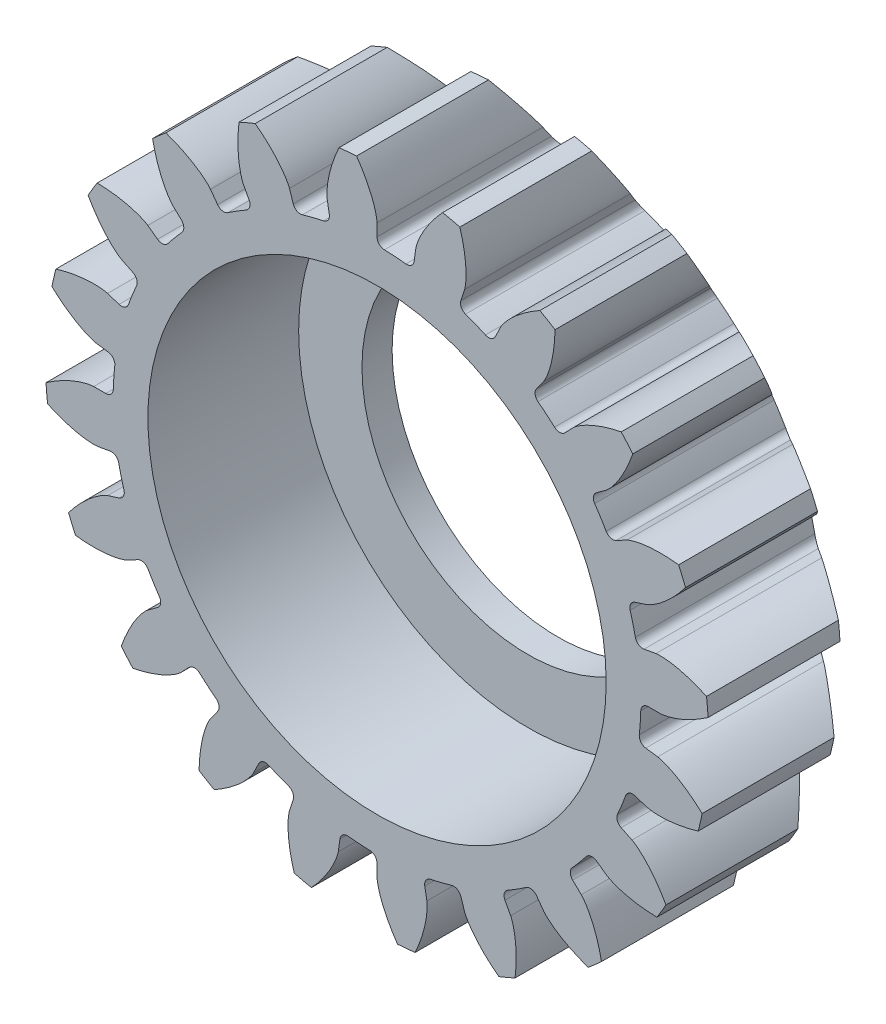
from build123d import *

# Parameters (mm, degrees)
BOSS_EXTRUDE3_DEPTH       = 6
FILLET1_R                 = 0.25
CIRPATTERN8_COUNT         = 20
CIRPATTERN8_COPY_1_DEPTH  = 6
CIRPATTERN8_COPY_2_DEPTH  = 6
CIRPATTERN8_COPY_3_DEPTH  = 6
CIRPATTERN8_COPY_4_DEPTH  = 6
CIRPATTERN8_COPY_5_DEPTH  = 6
CIRPATTERN8_COPY_6_DEPTH  = 6
CIRPATTERN8_COPY_7_DEPTH  = 6
CIRPATTERN8_COPY_8_DEPTH  = 6
CIRPATTERN8_COPY_9_DEPTH  = 6
CIRPATTERN8_COPY_10_DEPTH = 6
CIRPATTERN8_COPY_11_DEPTH = 6
CIRPATTERN8_COPY_12_DEPTH = 6
CIRPATTERN8_COPY_13_DEPTH = 6
CIRPATTERN8_COPY_14_DEPTH = 6
CIRPATTERN8_COPY_15_DEPTH = 6
CIRPATTERN8_COPY_16_DEPTH = 6
CIRPATTERN8_COPY_17_DEPTH = 6
CIRPATTERN8_COPY_18_DEPTH = 6
CIRPATTERN8_COPY_19_DEPTH = 6
FILLET1_OF_CIRPATTERN8_R  = 0.25
SKETCH3_R                 = 7.6
CUT_EXTRUDE2_DEPTH        = 7.0000001
SKETCH6_R                 = 7.6
SKETCH6_R_2               = 5.5
BOSS_EXTRUDE5_DEPTH       = 1


with BuildPart() as part:
    # Sketch1 → Boss-Extrude3 (new body)
    with BuildSketch(Plane.XY):
        with BuildLine():
            Line((8.75, 0), (9.396926208, 0))
            add(Edge.make_bspline(
                [(9.396926208, 0), (9.403873385, 0.000147014), (9.423343335, 0.001014311), (9.460070906, 0.004449694), (9.519753567, 0.012596883), (9.595337479, 0.026698157), (9.692315433, 0.04916848), (9.805467589, 0.081058111), (9.928458206, 0.121729349), (10.060578251, 0.171978374), (10.190725417, 0.227360837), (10.318851863, 0.287431588), (10.444850985, 0.351585639), (10.595383311, 0.434313207), (10.745012763, 0.523787061), (10.861917766, 0.599620812), (10.947597548, 0.658189386), (10.978959632, 0.680033385)],
                knots=[0, 0, 0, 0, 0, 0.005376748, 0.015083688, 0.02853182, 0.046610139, 0.064854849, 0.092110525, 0.119476175, 0.146842495, 0.174208853, 0.201574955, 0.228941013, 0.256307345, 0.307035032, 0.336624535, 0.336624535, 0.336624535, 0.336624535, 0.336624535], degree=4))
            ThreePointArc((10.978959632, 0.680033385), (10.968951272, 0.825898301), (10.957005057, 0.971617307))
            Line((10.957005057, 0.971617307), (8.715799477, 0.772877403))
            ThreePointArc((8.715799477, 0.772877403), (8.741445688, 0.386816868), (8.75, 0))
        make_face()
        with BuildLine():
            ThreePointArc((-8.715799477, -0.772877403), (0.386816868, -8.741445688), (8.75, 0))
            ThreePointArc((8.75, 0), (8.741445688, 0.386816868), (8.715799477, 0.772877403))
            Line((8.715799477, 0.772877403), (-8.715799477, -0.772877403))
        make_face()
        with BuildLine():
            Line((-8.715799477, -0.772877403), (8.715799477, 0.772877403))
            ThreePointArc((8.715799477, 0.772877403), (-0.772877403, 8.715799477), (-8.715799477, -0.772877403))
        make_face()
    boss_extrude3 = extrude(amount=BOSS_EXTRUDE3_DEPTH)

    # Mirror2: Boss-Extrude3 across plane
    add(boss_extrude3.mirror(Plane(origin=(0, 0, 6), x_dir=(0, 0, 1), z_dir=(0.088328846, -0.996091369, 0))))

    # Fillet1
    fillet1_edges = [part.edges().sort_by_distance(p)[0] for p in [
        (8.75, 0, 3),
        (8.613465262, 1.539713021, 3),
    ]]
    fillet(fillet1_edges, radius=FILLET1_R)

    # CirPattern8: Boss-Extrude3 ×20 about axis
    cirpattern8_axis = Axis((0, 0, 6), (0, 0, -1))
    for i in range(1, CIRPATTERN8_COUNT):
        add(boss_extrude3.rotate(cirpattern8_axis, i * 360 / CIRPATTERN8_COUNT))

    # CirPattern8 copy 1 sketch → CirPattern8 copy 1 (add)
    with BuildSketch(Plane(origin=(0, 0, 0), x_dir=(0.990593115, -0.136840348, 0), z_dir=(0, 0, 1))):
        with BuildLine():
            Line((8.75, 0), (9.396926208, 0))
            add(Edge.make_bspline(
                [(9.396926208, 0), (9.403873385, -0.000147014), (9.423343335, -0.001014311), (9.460070906, -0.004449694), (9.519753567, -0.012596883), (9.595337479, -0.026698157), (9.692315433, -0.04916848), (9.805467589, -0.081058111), (9.928458206, -0.121729349), (10.060578251, -0.171978374), (10.190725417, -0.227360837), (10.318851863, -0.287431588), (10.444850985, -0.351585639), (10.595383311, -0.434313207), (10.745012763, -0.523787061), (10.861917766, -0.599620812), (10.947597548, -0.658189386), (10.978959632, -0.680033385)],
                knots=[0, 0, 0, 0, 0, 0.005376748, 0.015083688, 0.02853182, 0.046610139, 0.064854849, 0.092110525, 0.119476175, 0.146842495, 0.174208853, 0.201574955, 0.228941013, 0.256307345, 0.307035032, 0.336624535, 0.336624535, 0.336624535, 0.336624535, 0.336624535], degree=4))
            ThreePointArc((10.978959632, -0.680033385), (10.968951272, -0.825898301), (10.957005057, -0.971617307))
            Line((10.957005057, -0.971617307), (8.715799477, -0.772877403))
            ThreePointArc((8.715799477, -0.772877403), (8.741445688, -0.386816868), (8.75, 0))
        make_face()
        with BuildLine():
            ThreePointArc((-8.715799477, 0.772877403), (0.386816868, 8.741445688), (8.75, 0))
            ThreePointArc((8.75, 0), (8.741445688, -0.386816868), (8.715799477, -0.772877403))
            Line((8.715799477, -0.772877403), (-8.715799477, 0.772877403))
        make_face()
        with BuildLine():
            Line((-8.715799477, 0.772877403), (8.715799477, -0.772877403))
            ThreePointArc((8.715799477, -0.772877403), (-0.772877403, -8.715799477), (-8.715799477, 0.772877403))
        make_face()
    extrude(amount=CIRPATTERN8_COPY_1_DEPTH)

    # CirPattern8 copy 2 sketch → CirPattern8 copy 2 (add)
    with BuildSketch(Plane(origin=(0, 0, 0), x_dir=(0.899824044, -0.436253012, 0), z_dir=(0, 0, 1))):
        with BuildLine():
            Line((8.75, 0), (9.396926208, 0))
            add(Edge.make_bspline(
                [(9.396926208, 0), (9.403873385, -0.000147014), (9.423343335, -0.001014311), (9.460070906, -0.004449694), (9.519753567, -0.012596883), (9.595337479, -0.026698157), (9.692315433, -0.04916848), (9.805467589, -0.081058111), (9.928458206, -0.121729349), (10.060578251, -0.171978374), (10.190725417, -0.227360837), (10.318851863, -0.287431588), (10.444850985, -0.351585639), (10.595383311, -0.434313207), (10.745012763, -0.523787061), (10.861917766, -0.599620812), (10.947597548, -0.658189386), (10.978959632, -0.680033385)],
                knots=[0, 0, 0, 0, 0, 0.005376748, 0.015083688, 0.02853182, 0.046610139, 0.064854849, 0.092110525, 0.119476175, 0.146842495, 0.174208853, 0.201574955, 0.228941013, 0.256307345, 0.307035032, 0.336624535, 0.336624535, 0.336624535, 0.336624535, 0.336624535], degree=4))
            ThreePointArc((10.978959632, -0.680033385), (10.968951272, -0.825898301), (10.957005057, -0.971617307))
            Line((10.957005057, -0.971617307), (8.715799477, -0.772877403))
            ThreePointArc((8.715799477, -0.772877403), (8.741445688, -0.386816868), (8.75, 0))
        make_face()
        with BuildLine():
            ThreePointArc((-8.715799477, 0.772877403), (0.386816868, 8.741445688), (8.75, 0))
            ThreePointArc((8.75, 0), (8.741445688, -0.386816868), (8.715799477, -0.772877403))
            Line((8.715799477, -0.772877403), (-8.715799477, 0.772877403))
        make_face()
        with BuildLine():
            Line((-8.715799477, 0.772877403), (8.715799477, -0.772877403))
            ThreePointArc((8.715799477, -0.772877403), (-0.772877403, -8.715799477), (-8.715799477, 0.772877403))
        make_face()
    extrude(amount=CIRPATTERN8_COPY_2_DEPTH)

    # CirPattern8 copy 3 sketch → CirPattern8 copy 3 (add)
    with BuildSketch(Plane(origin=(0, 0, 0), x_dir=(0.720973926, -0.692962191, 0), z_dir=(0, 0, 1))):
        with BuildLine():
            Line((8.75, 0), (9.396926208, 0))
            add(Edge.make_bspline(
                [(9.396926208, 0), (9.403873385, -0.000147014), (9.423343335, -0.001014311), (9.460070906, -0.004449694), (9.519753567, -0.012596883), (9.595337479, -0.026698157), (9.692315433, -0.04916848), (9.805467589, -0.081058111), (9.928458206, -0.121729349), (10.060578251, -0.171978374), (10.190725417, -0.227360837), (10.318851863, -0.287431588), (10.444850985, -0.351585639), (10.595383311, -0.434313207), (10.745012763, -0.523787061), (10.861917766, -0.599620812), (10.947597548, -0.658189386), (10.978959632, -0.680033385)],
                knots=[0, 0, 0, 0, 0, 0.005376748, 0.015083688, 0.02853182, 0.046610139, 0.064854849, 0.092110525, 0.119476175, 0.146842495, 0.174208853, 0.201574955, 0.228941013, 0.256307345, 0.307035032, 0.336624535, 0.336624535, 0.336624535, 0.336624535, 0.336624535], degree=4))
            ThreePointArc((10.978959632, -0.680033385), (10.968951272, -0.825898301), (10.957005057, -0.971617307))
            Line((10.957005057, -0.971617307), (8.715799477, -0.772877403))
            ThreePointArc((8.715799477, -0.772877403), (8.741445688, -0.386816868), (8.75, 0))
        make_face()
        with BuildLine():
            ThreePointArc((-8.715799477, 0.772877403), (0.386816868, 8.741445688), (8.75, 0))
            ThreePointArc((8.75, 0), (8.741445688, -0.386816868), (8.715799477, -0.772877403))
            Line((8.715799477, -0.772877403), (-8.715799477, 0.772877403))
        make_face()
        with BuildLine():
            Line((-8.715799477, 0.772877403), (8.715799477, -0.772877403))
            ThreePointArc((8.715799477, -0.772877403), (-0.772877403, -8.715799477), (-8.715799477, 0.772877403))
        make_face()
    extrude(amount=CIRPATTERN8_COPY_3_DEPTH)

    # CirPattern8 copy 4 sketch → CirPattern8 copy 4 (add)
    with BuildSketch(Plane(origin=(0, 0, 0), x_dir=(0.471549857, -0.881839403, 0), z_dir=(0, 0, 1))):
        with BuildLine():
            Line((8.75, 0), (9.396926208, 0))
            add(Edge.make_bspline(
                [(9.396926208, 0), (9.403873385, -0.000147014), (9.423343335, -0.001014311), (9.460070906, -0.004449694), (9.519753567, -0.012596883), (9.595337479, -0.026698157), (9.692315433, -0.04916848), (9.805467589, -0.081058111), (9.928458206, -0.121729349), (10.060578251, -0.171978374), (10.190725417, -0.227360837), (10.318851863, -0.287431588), (10.444850985, -0.351585639), (10.595383311, -0.434313207), (10.745012763, -0.523787061), (10.861917766, -0.599620812), (10.947597548, -0.658189386), (10.978959632, -0.680033385)],
                knots=[0, 0, 0, 0, 0, 0.005376748, 0.015083688, 0.02853182, 0.046610139, 0.064854849, 0.092110525, 0.119476175, 0.146842495, 0.174208853, 0.201574955, 0.228941013, 0.256307345, 0.307035032, 0.336624535, 0.336624535, 0.336624535, 0.336624535, 0.336624535], degree=4))
            ThreePointArc((10.978959632, -0.680033385), (10.968951272, -0.825898301), (10.957005057, -0.971617307))
            Line((10.957005057, -0.971617307), (8.715799477, -0.772877403))
            ThreePointArc((8.715799477, -0.772877403), (8.741445688, -0.386816868), (8.75, 0))
        make_face()
        with BuildLine():
            ThreePointArc((-8.715799477, 0.772877403), (0.386816868, 8.741445688), (8.75, 0))
            ThreePointArc((8.75, 0), (8.741445688, -0.386816868), (8.715799477, -0.772877403))
            Line((8.715799477, -0.772877403), (-8.715799477, 0.772877403))
        make_face()
        with BuildLine():
            Line((-8.715799477, 0.772877403), (8.715799477, -0.772877403))
            ThreePointArc((8.715799477, -0.772877403), (-0.772877403, -8.715799477), (-8.715799477, 0.772877403))
        make_face()
    extrude(amount=CIRPATTERN8_COPY_4_DEPTH)

    # CirPattern8 copy 5 sketch → CirPattern8 copy 5 (add)
    with BuildSketch(Plane(origin=(0, 0, 0), x_dir=(0.175967202, -0.98439603, 0), z_dir=(0, 0, 1))):
        with BuildLine():
            Line((8.75, 0), (9.396926208, 0))
            add(Edge.make_bspline(
                [(9.396926208, 0), (9.403873385, -0.000147014), (9.423343335, -0.001014311), (9.460070906, -0.004449694), (9.519753567, -0.012596883), (9.595337479, -0.026698157), (9.692315433, -0.04916848), (9.805467589, -0.081058111), (9.928458206, -0.121729349), (10.060578251, -0.171978374), (10.190725417, -0.227360837), (10.318851863, -0.287431588), (10.444850985, -0.351585639), (10.595383311, -0.434313207), (10.745012763, -0.523787061), (10.861917766, -0.599620812), (10.947597548, -0.658189386), (10.978959632, -0.680033385)],
                knots=[0, 0, 0, 0, 0, 0.005376748, 0.015083688, 0.02853182, 0.046610139, 0.064854849, 0.092110525, 0.119476175, 0.146842495, 0.174208853, 0.201574955, 0.228941013, 0.256307345, 0.307035032, 0.336624535, 0.336624535, 0.336624535, 0.336624535, 0.336624535], degree=4))
            ThreePointArc((10.978959632, -0.680033385), (10.968951272, -0.825898301), (10.957005057, -0.971617307))
            Line((10.957005057, -0.971617307), (8.715799477, -0.772877403))
            ThreePointArc((8.715799477, -0.772877403), (8.741445688, -0.386816868), (8.75, 0))
        make_face()
        with BuildLine():
            ThreePointArc((-8.715799477, 0.772877403), (0.386816868, 8.741445688), (8.75, 0))
            ThreePointArc((8.75, 0), (8.741445688, -0.386816868), (8.715799477, -0.772877403))
            Line((8.715799477, -0.772877403), (-8.715799477, 0.772877403))
        make_face()
        with BuildLine():
            Line((-8.715799477, 0.772877403), (8.715799477, -0.772877403))
            ThreePointArc((8.715799477, -0.772877403), (-0.772877403, -8.715799477), (-8.715799477, 0.772877403))
        make_face()
    extrude(amount=CIRPATTERN8_COPY_5_DEPTH)

    # CirPattern8 copy 6 sketch → CirPattern8 copy 6 (add)
    with BuildSketch(Plane(origin=(0, 0, 0), x_dir=(-0.136840348, -0.990593115, 0), z_dir=(0, 0, 1))):
        with BuildLine():
            Line((8.75, 0), (9.396926208, 0))
            add(Edge.make_bspline(
                [(9.396926208, 0), (9.403873385, -0.000147014), (9.423343335, -0.001014311), (9.460070906, -0.004449694), (9.519753567, -0.012596883), (9.595337479, -0.026698157), (9.692315433, -0.04916848), (9.805467589, -0.081058111), (9.928458206, -0.121729349), (10.060578251, -0.171978374), (10.190725417, -0.227360837), (10.318851863, -0.287431588), (10.444850985, -0.351585639), (10.595383311, -0.434313207), (10.745012763, -0.523787061), (10.861917766, -0.599620812), (10.947597548, -0.658189386), (10.978959632, -0.680033385)],
                knots=[0, 0, 0, 0, 0, 0.005376748, 0.015083688, 0.02853182, 0.046610139, 0.064854849, 0.092110525, 0.119476175, 0.146842495, 0.174208853, 0.201574955, 0.228941013, 0.256307345, 0.307035032, 0.336624535, 0.336624535, 0.336624535, 0.336624535, 0.336624535], degree=4))
            ThreePointArc((10.978959632, -0.680033385), (10.968951272, -0.825898301), (10.957005057, -0.971617307))
            Line((10.957005057, -0.971617307), (8.715799477, -0.772877403))
            ThreePointArc((8.715799477, -0.772877403), (8.741445688, -0.386816868), (8.75, 0))
        make_face()
        with BuildLine():
            ThreePointArc((-8.715799477, 0.772877403), (0.386816868, 8.741445688), (8.75, 0))
            ThreePointArc((8.75, 0), (8.741445688, -0.386816868), (8.715799477, -0.772877403))
            Line((8.715799477, -0.772877403), (-8.715799477, 0.772877403))
        make_face()
        with BuildLine():
            Line((-8.715799477, 0.772877403), (8.715799477, -0.772877403))
            ThreePointArc((8.715799477, -0.772877403), (-0.772877403, -8.715799477), (-8.715799477, 0.772877403))
        make_face()
    extrude(amount=CIRPATTERN8_COPY_6_DEPTH)

    # CirPattern8 copy 7 sketch → CirPattern8 copy 7 (add)
    with BuildSketch(Plane(origin=(0, 0, 0), x_dir=(-0.436253012, -0.899824044, 0), z_dir=(0, 0, 1))):
        with BuildLine():
            Line((8.75, 0), (9.396926208, 0))
            add(Edge.make_bspline(
                [(9.396926208, 0), (9.403873385, -0.000147014), (9.423343335, -0.001014311), (9.460070906, -0.004449694), (9.519753567, -0.012596883), (9.595337479, -0.026698157), (9.692315433, -0.04916848), (9.805467589, -0.081058111), (9.928458206, -0.121729349), (10.060578251, -0.171978374), (10.190725417, -0.227360837), (10.318851863, -0.287431588), (10.444850985, -0.351585639), (10.595383311, -0.434313207), (10.745012763, -0.523787061), (10.861917766, -0.599620812), (10.947597548, -0.658189386), (10.978959632, -0.680033385)],
                knots=[0, 0, 0, 0, 0, 0.005376748, 0.015083688, 0.02853182, 0.046610139, 0.064854849, 0.092110525, 0.119476175, 0.146842495, 0.174208853, 0.201574955, 0.228941013, 0.256307345, 0.307035032, 0.336624535, 0.336624535, 0.336624535, 0.336624535, 0.336624535], degree=4))
            ThreePointArc((10.978959632, -0.680033385), (10.968951272, -0.825898301), (10.957005057, -0.971617307))
            Line((10.957005057, -0.971617307), (8.715799477, -0.772877403))
            ThreePointArc((8.715799477, -0.772877403), (8.741445688, -0.386816868), (8.75, 0))
        make_face()
        with BuildLine():
            ThreePointArc((-8.715799477, 0.772877403), (0.386816868, 8.741445688), (8.75, 0))
            ThreePointArc((8.75, 0), (8.741445688, -0.386816868), (8.715799477, -0.772877403))
            Line((8.715799477, -0.772877403), (-8.715799477, 0.772877403))
        make_face()
        with BuildLine():
            Line((-8.715799477, 0.772877403), (8.715799477, -0.772877403))
            ThreePointArc((8.715799477, -0.772877403), (-0.772877403, -8.715799477), (-8.715799477, 0.772877403))
        make_face()
    extrude(amount=CIRPATTERN8_COPY_7_DEPTH)

    # CirPattern8 copy 8 sketch → CirPattern8 copy 8 (add)
    with BuildSketch(Plane(origin=(0, 0, 0), x_dir=(-0.692962191, -0.720973926, 0), z_dir=(0, 0, 1))):
        with BuildLine():
            Line((8.75, 0), (9.396926208, 0))
            add(Edge.make_bspline(
                [(9.396926208, 0), (9.403873385, -0.000147014), (9.423343335, -0.001014311), (9.460070906, -0.004449694), (9.519753567, -0.012596883), (9.595337479, -0.026698157), (9.692315433, -0.04916848), (9.805467589, -0.081058111), (9.928458206, -0.121729349), (10.060578251, -0.171978374), (10.190725417, -0.227360837), (10.318851863, -0.287431588), (10.444850985, -0.351585639), (10.595383311, -0.434313207), (10.745012763, -0.523787061), (10.861917766, -0.599620812), (10.947597548, -0.658189386), (10.978959632, -0.680033385)],
                knots=[0, 0, 0, 0, 0, 0.005376748, 0.015083688, 0.02853182, 0.046610139, 0.064854849, 0.092110525, 0.119476175, 0.146842495, 0.174208853, 0.201574955, 0.228941013, 0.256307345, 0.307035032, 0.336624535, 0.336624535, 0.336624535, 0.336624535, 0.336624535], degree=4))
            ThreePointArc((10.978959632, -0.680033385), (10.968951272, -0.825898301), (10.957005057, -0.971617307))
            Line((10.957005057, -0.971617307), (8.715799477, -0.772877403))
            ThreePointArc((8.715799477, -0.772877403), (8.741445688, -0.386816868), (8.75, 0))
        make_face()
        with BuildLine():
            ThreePointArc((-8.715799477, 0.772877403), (0.386816868, 8.741445688), (8.75, 0))
            ThreePointArc((8.75, 0), (8.741445688, -0.386816868), (8.715799477, -0.772877403))
            Line((8.715799477, -0.772877403), (-8.715799477, 0.772877403))
        make_face()
        with BuildLine():
            Line((-8.715799477, 0.772877403), (8.715799477, -0.772877403))
            ThreePointArc((8.715799477, -0.772877403), (-0.772877403, -8.715799477), (-8.715799477, 0.772877403))
        make_face()
    extrude(amount=CIRPATTERN8_COPY_8_DEPTH)

    # CirPattern8 copy 9 sketch → CirPattern8 copy 9 (add)
    with BuildSketch(Plane(origin=(0, 0, 0), x_dir=(-0.881839403, -0.471549857, 0), z_dir=(0, 0, 1))):
        with BuildLine():
            Line((8.75, 0), (9.396926208, 0))
            add(Edge.make_bspline(
                [(9.396926208, 0), (9.403873385, -0.000147014), (9.423343335, -0.001014311), (9.460070906, -0.004449694), (9.519753567, -0.012596883), (9.595337479, -0.026698157), (9.692315433, -0.04916848), (9.805467589, -0.081058111), (9.928458206, -0.121729349), (10.060578251, -0.171978374), (10.190725417, -0.227360837), (10.318851863, -0.287431588), (10.444850985, -0.351585639), (10.595383311, -0.434313207), (10.745012763, -0.523787061), (10.861917766, -0.599620812), (10.947597548, -0.658189386), (10.978959632, -0.680033385)],
                knots=[0, 0, 0, 0, 0, 0.005376748, 0.015083688, 0.02853182, 0.046610139, 0.064854849, 0.092110525, 0.119476175, 0.146842495, 0.174208853, 0.201574955, 0.228941013, 0.256307345, 0.307035032, 0.336624535, 0.336624535, 0.336624535, 0.336624535, 0.336624535], degree=4))
            ThreePointArc((10.978959632, -0.680033385), (10.968951272, -0.825898301), (10.957005057, -0.971617307))
            Line((10.957005057, -0.971617307), (8.715799477, -0.772877403))
            ThreePointArc((8.715799477, -0.772877403), (8.741445688, -0.386816868), (8.75, 0))
        make_face()
        with BuildLine():
            ThreePointArc((-8.715799477, 0.772877403), (0.386816868, 8.741445688), (8.75, 0))
            ThreePointArc((8.75, 0), (8.741445688, -0.386816868), (8.715799477, -0.772877403))
            Line((8.715799477, -0.772877403), (-8.715799477, 0.772877403))
        make_face()
        with BuildLine():
            Line((-8.715799477, 0.772877403), (8.715799477, -0.772877403))
            ThreePointArc((8.715799477, -0.772877403), (-0.772877403, -8.715799477), (-8.715799477, 0.772877403))
        make_face()
    extrude(amount=CIRPATTERN8_COPY_9_DEPTH)

    # CirPattern8 copy 10 sketch → CirPattern8 copy 10 (add)
    with BuildSketch(Plane(origin=(0, 0, 0), x_dir=(-0.98439603, -0.175967202, 0), z_dir=(0, 0, 1))):
        with BuildLine():
            Line((8.75, 0), (9.396926208, 0))
            add(Edge.make_bspline(
                [(9.396926208, 0), (9.403873385, -0.000147014), (9.423343335, -0.001014311), (9.460070906, -0.004449694), (9.519753567, -0.012596883), (9.595337479, -0.026698157), (9.692315433, -0.04916848), (9.805467589, -0.081058111), (9.928458206, -0.121729349), (10.060578251, -0.171978374), (10.190725417, -0.227360837), (10.318851863, -0.287431588), (10.444850985, -0.351585639), (10.595383311, -0.434313207), (10.745012763, -0.523787061), (10.861917766, -0.599620812), (10.947597548, -0.658189386), (10.978959632, -0.680033385)],
                knots=[0, 0, 0, 0, 0, 0.005376748, 0.015083688, 0.02853182, 0.046610139, 0.064854849, 0.092110525, 0.119476175, 0.146842495, 0.174208853, 0.201574955, 0.228941013, 0.256307345, 0.307035032, 0.336624535, 0.336624535, 0.336624535, 0.336624535, 0.336624535], degree=4))
            ThreePointArc((10.978959632, -0.680033385), (10.968951272, -0.825898301), (10.957005057, -0.971617307))
            Line((10.957005057, -0.971617307), (8.715799477, -0.772877403))
            ThreePointArc((8.715799477, -0.772877403), (8.741445688, -0.386816868), (8.75, 0))
        make_face()
        with BuildLine():
            ThreePointArc((-8.715799477, 0.772877403), (0.386816868, 8.741445688), (8.75, 0))
            ThreePointArc((8.75, 0), (8.741445688, -0.386816868), (8.715799477, -0.772877403))
            Line((8.715799477, -0.772877403), (-8.715799477, 0.772877403))
        make_face()
        with BuildLine():
            Line((-8.715799477, 0.772877403), (8.715799477, -0.772877403))
            ThreePointArc((8.715799477, -0.772877403), (-0.772877403, -8.715799477), (-8.715799477, 0.772877403))
        make_face()
    extrude(amount=CIRPATTERN8_COPY_10_DEPTH)

    # CirPattern8 copy 11 sketch → CirPattern8 copy 11 (add)
    with BuildSketch(Plane(origin=(0, 0, 0), x_dir=(-0.990593115, 0.136840348, 0), z_dir=(0, 0, 1))):
        with BuildLine():
            Line((8.75, 0), (9.396926208, 0))
            add(Edge.make_bspline(
                [(9.396926208, 0), (9.403873385, -0.000147014), (9.423343335, -0.001014311), (9.460070906, -0.004449694), (9.519753567, -0.012596883), (9.595337479, -0.026698157), (9.692315433, -0.04916848), (9.805467589, -0.081058111), (9.928458206, -0.121729349), (10.060578251, -0.171978374), (10.190725417, -0.227360837), (10.318851863, -0.287431588), (10.444850985, -0.351585639), (10.595383311, -0.434313207), (10.745012763, -0.523787061), (10.861917766, -0.599620812), (10.947597548, -0.658189386), (10.978959632, -0.680033385)],
                knots=[0, 0, 0, 0, 0, 0.005376748, 0.015083688, 0.02853182, 0.046610139, 0.064854849, 0.092110525, 0.119476175, 0.146842495, 0.174208853, 0.201574955, 0.228941013, 0.256307345, 0.307035032, 0.336624535, 0.336624535, 0.336624535, 0.336624535, 0.336624535], degree=4))
            ThreePointArc((10.978959632, -0.680033385), (10.968951272, -0.825898301), (10.957005057, -0.971617307))
            Line((10.957005057, -0.971617307), (8.715799477, -0.772877403))
            ThreePointArc((8.715799477, -0.772877403), (8.741445688, -0.386816868), (8.75, 0))
        make_face()
        with BuildLine():
            ThreePointArc((-8.715799477, 0.772877403), (0.386816868, 8.741445688), (8.75, 0))
            ThreePointArc((8.75, 0), (8.741445688, -0.386816868), (8.715799477, -0.772877403))
            Line((8.715799477, -0.772877403), (-8.715799477, 0.772877403))
        make_face()
        with BuildLine():
            Line((-8.715799477, 0.772877403), (8.715799477, -0.772877403))
            ThreePointArc((8.715799477, -0.772877403), (-0.772877403, -8.715799477), (-8.715799477, 0.772877403))
        make_face()
    extrude(amount=CIRPATTERN8_COPY_11_DEPTH)

    # CirPattern8 copy 12 sketch → CirPattern8 copy 12 (add)
    with BuildSketch(Plane(origin=(0, 0, 0), x_dir=(-0.899824044, 0.436253012, 0), z_dir=(0, 0, 1))):
        with BuildLine():
            Line((8.75, 0), (9.396926208, 0))
            add(Edge.make_bspline(
                [(9.396926208, 0), (9.403873385, -0.000147014), (9.423343335, -0.001014311), (9.460070906, -0.004449694), (9.519753567, -0.012596883), (9.595337479, -0.026698157), (9.692315433, -0.04916848), (9.805467589, -0.081058111), (9.928458206, -0.121729349), (10.060578251, -0.171978374), (10.190725417, -0.227360837), (10.318851863, -0.287431588), (10.444850985, -0.351585639), (10.595383311, -0.434313207), (10.745012763, -0.523787061), (10.861917766, -0.599620812), (10.947597548, -0.658189386), (10.978959632, -0.680033385)],
                knots=[0, 0, 0, 0, 0, 0.005376748, 0.015083688, 0.02853182, 0.046610139, 0.064854849, 0.092110525, 0.119476175, 0.146842495, 0.174208853, 0.201574955, 0.228941013, 0.256307345, 0.307035032, 0.336624535, 0.336624535, 0.336624535, 0.336624535, 0.336624535], degree=4))
            ThreePointArc((10.978959632, -0.680033385), (10.968951272, -0.825898301), (10.957005057, -0.971617307))
            Line((10.957005057, -0.971617307), (8.715799477, -0.772877403))
            ThreePointArc((8.715799477, -0.772877403), (8.741445688, -0.386816868), (8.75, 0))
        make_face()
        with BuildLine():
            ThreePointArc((-8.715799477, 0.772877403), (0.386816868, 8.741445688), (8.75, 0))
            ThreePointArc((8.75, 0), (8.741445688, -0.386816868), (8.715799477, -0.772877403))
            Line((8.715799477, -0.772877403), (-8.715799477, 0.772877403))
        make_face()
        with BuildLine():
            Line((-8.715799477, 0.772877403), (8.715799477, -0.772877403))
            ThreePointArc((8.715799477, -0.772877403), (-0.772877403, -8.715799477), (-8.715799477, 0.772877403))
        make_face()
    extrude(amount=CIRPATTERN8_COPY_12_DEPTH)

    # CirPattern8 copy 13 sketch → CirPattern8 copy 13 (add)
    with BuildSketch(Plane(origin=(0, 0, 0), x_dir=(-0.720973926, 0.692962191, 0), z_dir=(0, 0, 1))):
        with BuildLine():
            Line((8.75, 0), (9.396926208, 0))
            add(Edge.make_bspline(
                [(9.396926208, 0), (9.403873385, -0.000147014), (9.423343335, -0.001014311), (9.460070906, -0.004449694), (9.519753567, -0.012596883), (9.595337479, -0.026698157), (9.692315433, -0.04916848), (9.805467589, -0.081058111), (9.928458206, -0.121729349), (10.060578251, -0.171978374), (10.190725417, -0.227360837), (10.318851863, -0.287431588), (10.444850985, -0.351585639), (10.595383311, -0.434313207), (10.745012763, -0.523787061), (10.861917766, -0.599620812), (10.947597548, -0.658189386), (10.978959632, -0.680033385)],
                knots=[0, 0, 0, 0, 0, 0.005376748, 0.015083688, 0.02853182, 0.046610139, 0.064854849, 0.092110525, 0.119476175, 0.146842495, 0.174208853, 0.201574955, 0.228941013, 0.256307345, 0.307035032, 0.336624535, 0.336624535, 0.336624535, 0.336624535, 0.336624535], degree=4))
            ThreePointArc((10.978959632, -0.680033385), (10.968951272, -0.825898301), (10.957005057, -0.971617307))
            Line((10.957005057, -0.971617307), (8.715799477, -0.772877403))
            ThreePointArc((8.715799477, -0.772877403), (8.741445688, -0.386816868), (8.75, 0))
        make_face()
        with BuildLine():
            ThreePointArc((-8.715799477, 0.772877403), (0.386816868, 8.741445688), (8.75, 0))
            ThreePointArc((8.75, 0), (8.741445688, -0.386816868), (8.715799477, -0.772877403))
            Line((8.715799477, -0.772877403), (-8.715799477, 0.772877403))
        make_face()
        with BuildLine():
            Line((-8.715799477, 0.772877403), (8.715799477, -0.772877403))
            ThreePointArc((8.715799477, -0.772877403), (-0.772877403, -8.715799477), (-8.715799477, 0.772877403))
        make_face()
    extrude(amount=CIRPATTERN8_COPY_13_DEPTH)

    # CirPattern8 copy 14 sketch → CirPattern8 copy 14 (add)
    with BuildSketch(Plane(origin=(0, 0, 0), x_dir=(-0.471549857, 0.881839403, 0), z_dir=(0, 0, 1))):
        with BuildLine():
            Line((8.75, 0), (9.396926208, 0))
            add(Edge.make_bspline(
                [(9.396926208, 0), (9.403873385, -0.000147014), (9.423343335, -0.001014311), (9.460070906, -0.004449694), (9.519753567, -0.012596883), (9.595337479, -0.026698157), (9.692315433, -0.04916848), (9.805467589, -0.081058111), (9.928458206, -0.121729349), (10.060578251, -0.171978374), (10.190725417, -0.227360837), (10.318851863, -0.287431588), (10.444850985, -0.351585639), (10.595383311, -0.434313207), (10.745012763, -0.523787061), (10.861917766, -0.599620812), (10.947597548, -0.658189386), (10.978959632, -0.680033385)],
                knots=[0, 0, 0, 0, 0, 0.005376748, 0.015083688, 0.02853182, 0.046610139, 0.064854849, 0.092110525, 0.119476175, 0.146842495, 0.174208853, 0.201574955, 0.228941013, 0.256307345, 0.307035032, 0.336624535, 0.336624535, 0.336624535, 0.336624535, 0.336624535], degree=4))
            ThreePointArc((10.978959632, -0.680033385), (10.968951272, -0.825898301), (10.957005057, -0.971617307))
            Line((10.957005057, -0.971617307), (8.715799477, -0.772877403))
            ThreePointArc((8.715799477, -0.772877403), (8.741445688, -0.386816868), (8.75, 0))
        make_face()
        with BuildLine():
            ThreePointArc((-8.715799477, 0.772877403), (0.386816868, 8.741445688), (8.75, 0))
            ThreePointArc((8.75, 0), (8.741445688, -0.386816868), (8.715799477, -0.772877403))
            Line((8.715799477, -0.772877403), (-8.715799477, 0.772877403))
        make_face()
        with BuildLine():
            Line((-8.715799477, 0.772877403), (8.715799477, -0.772877403))
            ThreePointArc((8.715799477, -0.772877403), (-0.772877403, -8.715799477), (-8.715799477, 0.772877403))
        make_face()
    extrude(amount=CIRPATTERN8_COPY_14_DEPTH)

    # CirPattern8 copy 15 sketch → CirPattern8 copy 15 (add)
    with BuildSketch(Plane(origin=(0, 0, 0), x_dir=(-0.175967202, 0.98439603, 0), z_dir=(0, 0, 1))):
        with BuildLine():
            Line((8.75, 0), (9.396926208, 0))
            add(Edge.make_bspline(
                [(9.396926208, 0), (9.403873385, -0.000147014), (9.423343335, -0.001014311), (9.460070906, -0.004449694), (9.519753567, -0.012596883), (9.595337479, -0.026698157), (9.692315433, -0.04916848), (9.805467589, -0.081058111), (9.928458206, -0.121729349), (10.060578251, -0.171978374), (10.190725417, -0.227360837), (10.318851863, -0.287431588), (10.444850985, -0.351585639), (10.595383311, -0.434313207), (10.745012763, -0.523787061), (10.861917766, -0.599620812), (10.947597548, -0.658189386), (10.978959632, -0.680033385)],
                knots=[0, 0, 0, 0, 0, 0.005376748, 0.015083688, 0.02853182, 0.046610139, 0.064854849, 0.092110525, 0.119476175, 0.146842495, 0.174208853, 0.201574955, 0.228941013, 0.256307345, 0.307035032, 0.336624535, 0.336624535, 0.336624535, 0.336624535, 0.336624535], degree=4))
            ThreePointArc((10.978959632, -0.680033385), (10.968951272, -0.825898301), (10.957005057, -0.971617307))
            Line((10.957005057, -0.971617307), (8.715799477, -0.772877403))
            ThreePointArc((8.715799477, -0.772877403), (8.741445688, -0.386816868), (8.75, 0))
        make_face()
        with BuildLine():
            ThreePointArc((-8.715799477, 0.772877403), (0.386816868, 8.741445688), (8.75, 0))
            ThreePointArc((8.75, 0), (8.741445688, -0.386816868), (8.715799477, -0.772877403))
            Line((8.715799477, -0.772877403), (-8.715799477, 0.772877403))
        make_face()
        with BuildLine():
            Line((-8.715799477, 0.772877403), (8.715799477, -0.772877403))
            ThreePointArc((8.715799477, -0.772877403), (-0.772877403, -8.715799477), (-8.715799477, 0.772877403))
        make_face()
    extrude(amount=CIRPATTERN8_COPY_15_DEPTH)

    # CirPattern8 copy 16 sketch → CirPattern8 copy 16 (add)
    with BuildSketch(Plane(origin=(0, 0, 0), x_dir=(0.136840348, 0.990593115, 0), z_dir=(0, 0, 1))):
        with BuildLine():
            Line((8.75, 0), (9.396926208, 0))
            add(Edge.make_bspline(
                [(9.396926208, 0), (9.403873385, -0.000147014), (9.423343335, -0.001014311), (9.460070906, -0.004449694), (9.519753567, -0.012596883), (9.595337479, -0.026698157), (9.692315433, -0.04916848), (9.805467589, -0.081058111), (9.928458206, -0.121729349), (10.060578251, -0.171978374), (10.190725417, -0.227360837), (10.318851863, -0.287431588), (10.444850985, -0.351585639), (10.595383311, -0.434313207), (10.745012763, -0.523787061), (10.861917766, -0.599620812), (10.947597548, -0.658189386), (10.978959632, -0.680033385)],
                knots=[0, 0, 0, 0, 0, 0.005376748, 0.015083688, 0.02853182, 0.046610139, 0.064854849, 0.092110525, 0.119476175, 0.146842495, 0.174208853, 0.201574955, 0.228941013, 0.256307345, 0.307035032, 0.336624535, 0.336624535, 0.336624535, 0.336624535, 0.336624535], degree=4))
            ThreePointArc((10.978959632, -0.680033385), (10.968951272, -0.825898301), (10.957005057, -0.971617307))
            Line((10.957005057, -0.971617307), (8.715799477, -0.772877403))
            ThreePointArc((8.715799477, -0.772877403), (8.741445688, -0.386816868), (8.75, 0))
        make_face()
        with BuildLine():
            ThreePointArc((-8.715799477, 0.772877403), (0.386816868, 8.741445688), (8.75, 0))
            ThreePointArc((8.75, 0), (8.741445688, -0.386816868), (8.715799477, -0.772877403))
            Line((8.715799477, -0.772877403), (-8.715799477, 0.772877403))
        make_face()
        with BuildLine():
            Line((-8.715799477, 0.772877403), (8.715799477, -0.772877403))
            ThreePointArc((8.715799477, -0.772877403), (-0.772877403, -8.715799477), (-8.715799477, 0.772877403))
        make_face()
    extrude(amount=CIRPATTERN8_COPY_16_DEPTH)

    # CirPattern8 copy 17 sketch → CirPattern8 copy 17 (add)
    with BuildSketch(Plane(origin=(0, 0, 0), x_dir=(0.436253012, 0.899824044, 0), z_dir=(0, 0, 1))):
        with BuildLine():
            Line((8.75, 0), (9.396926208, 0))
            add(Edge.make_bspline(
                [(9.396926208, 0), (9.403873385, -0.000147014), (9.423343335, -0.001014311), (9.460070906, -0.004449694), (9.519753567, -0.012596883), (9.595337479, -0.026698157), (9.692315433, -0.04916848), (9.805467589, -0.081058111), (9.928458206, -0.121729349), (10.060578251, -0.171978374), (10.190725417, -0.227360837), (10.318851863, -0.287431588), (10.444850985, -0.351585639), (10.595383311, -0.434313207), (10.745012763, -0.523787061), (10.861917766, -0.599620812), (10.947597548, -0.658189386), (10.978959632, -0.680033385)],
                knots=[0, 0, 0, 0, 0, 0.005376748, 0.015083688, 0.02853182, 0.046610139, 0.064854849, 0.092110525, 0.119476175, 0.146842495, 0.174208853, 0.201574955, 0.228941013, 0.256307345, 0.307035032, 0.336624535, 0.336624535, 0.336624535, 0.336624535, 0.336624535], degree=4))
            ThreePointArc((10.978959632, -0.680033385), (10.968951272, -0.825898301), (10.957005057, -0.971617307))
            Line((10.957005057, -0.971617307), (8.715799477, -0.772877403))
            ThreePointArc((8.715799477, -0.772877403), (8.741445688, -0.386816868), (8.75, 0))
        make_face()
        with BuildLine():
            ThreePointArc((-8.715799477, 0.772877403), (0.386816868, 8.741445688), (8.75, 0))
            ThreePointArc((8.75, 0), (8.741445688, -0.386816868), (8.715799477, -0.772877403))
            Line((8.715799477, -0.772877403), (-8.715799477, 0.772877403))
        make_face()
        with BuildLine():
            Line((-8.715799477, 0.772877403), (8.715799477, -0.772877403))
            ThreePointArc((8.715799477, -0.772877403), (-0.772877403, -8.715799477), (-8.715799477, 0.772877403))
        make_face()
    extrude(amount=CIRPATTERN8_COPY_17_DEPTH)

    # CirPattern8 copy 18 sketch → CirPattern8 copy 18 (add)
    with BuildSketch(Plane(origin=(0, 0, 0), x_dir=(0.692962191, 0.720973926, 0), z_dir=(0, 0, 1))):
        with BuildLine():
            Line((8.75, 0), (9.396926208, 0))
            add(Edge.make_bspline(
                [(9.396926208, 0), (9.403873385, -0.000147014), (9.423343335, -0.001014311), (9.460070906, -0.004449694), (9.519753567, -0.012596883), (9.595337479, -0.026698157), (9.692315433, -0.04916848), (9.805467589, -0.081058111), (9.928458206, -0.121729349), (10.060578251, -0.171978374), (10.190725417, -0.227360837), (10.318851863, -0.287431588), (10.444850985, -0.351585639), (10.595383311, -0.434313207), (10.745012763, -0.523787061), (10.861917766, -0.599620812), (10.947597548, -0.658189386), (10.978959632, -0.680033385)],
                knots=[0, 0, 0, 0, 0, 0.005376748, 0.015083688, 0.02853182, 0.046610139, 0.064854849, 0.092110525, 0.119476175, 0.146842495, 0.174208853, 0.201574955, 0.228941013, 0.256307345, 0.307035032, 0.336624535, 0.336624535, 0.336624535, 0.336624535, 0.336624535], degree=4))
            ThreePointArc((10.978959632, -0.680033385), (10.968951272, -0.825898301), (10.957005057, -0.971617307))
            Line((10.957005057, -0.971617307), (8.715799477, -0.772877403))
            ThreePointArc((8.715799477, -0.772877403), (8.741445688, -0.386816868), (8.75, 0))
        make_face()
        with BuildLine():
            ThreePointArc((-8.715799477, 0.772877403), (0.386816868, 8.741445688), (8.75, 0))
            ThreePointArc((8.75, 0), (8.741445688, -0.386816868), (8.715799477, -0.772877403))
            Line((8.715799477, -0.772877403), (-8.715799477, 0.772877403))
        make_face()
        with BuildLine():
            Line((-8.715799477, 0.772877403), (8.715799477, -0.772877403))
            ThreePointArc((8.715799477, -0.772877403), (-0.772877403, -8.715799477), (-8.715799477, 0.772877403))
        make_face()
    extrude(amount=CIRPATTERN8_COPY_18_DEPTH)

    # CirPattern8 copy 19 sketch → CirPattern8 copy 19 (add)
    with BuildSketch(Plane(origin=(0, 0, 0), x_dir=(0.881839403, 0.471549857, 0), z_dir=(0, 0, 1))):
        with BuildLine():
            Line((8.75, 0), (9.396926208, 0))
            add(Edge.make_bspline(
                [(9.396926208, 0), (9.403873385, -0.000147014), (9.423343335, -0.001014311), (9.460070906, -0.004449694), (9.519753567, -0.012596883), (9.595337479, -0.026698157), (9.692315433, -0.04916848), (9.805467589, -0.081058111), (9.928458206, -0.121729349), (10.060578251, -0.171978374), (10.190725417, -0.227360837), (10.318851863, -0.287431588), (10.444850985, -0.351585639), (10.595383311, -0.434313207), (10.745012763, -0.523787061), (10.861917766, -0.599620812), (10.947597548, -0.658189386), (10.978959632, -0.680033385)],
                knots=[0, 0, 0, 0, 0, 0.005376748, 0.015083688, 0.02853182, 0.046610139, 0.064854849, 0.092110525, 0.119476175, 0.146842495, 0.174208853, 0.201574955, 0.228941013, 0.256307345, 0.307035032, 0.336624535, 0.336624535, 0.336624535, 0.336624535, 0.336624535], degree=4))
            ThreePointArc((10.978959632, -0.680033385), (10.968951272, -0.825898301), (10.957005057, -0.971617307))
            Line((10.957005057, -0.971617307), (8.715799477, -0.772877403))
            ThreePointArc((8.715799477, -0.772877403), (8.741445688, -0.386816868), (8.75, 0))
        make_face()
        with BuildLine():
            ThreePointArc((-8.715799477, 0.772877403), (0.386816868, 8.741445688), (8.75, 0))
            ThreePointArc((8.75, 0), (8.741445688, -0.386816868), (8.715799477, -0.772877403))
            Line((8.715799477, -0.772877403), (-8.715799477, 0.772877403))
        make_face()
        with BuildLine():
            Line((-8.715799477, 0.772877403), (8.715799477, -0.772877403))
            ThreePointArc((8.715799477, -0.772877403), (-0.772877403, -8.715799477), (-8.715799477, 0.772877403))
        make_face()
    extrude(amount=CIRPATTERN8_COPY_19_DEPTH)

    # Fillet1 of CirPattern8
    fillet1_of_cirpattern8_edges = [part.edges().sort_by_distance(p)[0] for p in [
        (8.321744518, -2.703898701, 3),
        (8.667689755, -1.197353044, 3),
        (7.078898701, -5.143120958, 3),
        (7.873460384, -3.817213851, 3),
        (5.143120958, -7.078898701, 3),
        (6.308521853, -6.06341917, 3),
        (2.703898701, -8.321744518, 3),
        (4.126061248, -7.716094775, 3),
        (0, -8.75, 3),
        (1.539713021, -8.613465262, 3),
        (-2.703898701, -8.321744518, 3),
        (-1.197353044, -8.667689755, 3),
        (-5.143120958, -7.078898701, 3),
        (-3.817213851, -7.873460384, 3),
        (-7.078898701, -5.143120958, 3),
        (-6.06341917, -6.308521853, 3),
        (-8.321744518, -2.703898701, 3),
        (-7.716094775, -4.126061248, 3),
        (-8.75, 0, 3),
        (-8.613465262, -1.539713021, 3),
        (-8.321744518, 2.703898701, 3),
        (-8.667689755, 1.197353044, 3),
        (-7.078898701, 5.143120958, 3),
        (-7.873460384, 3.817213851, 3),
        (-5.143120958, 7.078898701, 3),
        (-6.308521853, 6.06341917, 3),
        (-2.703898701, 8.321744518, 3),
        (-4.126061248, 7.716094775, 3),
        (0, 8.75, 3),
        (-1.539713021, 8.613465262, 3),
        (2.703898701, 8.321744518, 3),
        (1.197353044, 8.667689755, 3),
        (5.143120958, 7.078898701, 3),
        (3.817213851, 7.873460384, 3),
        (7.078898701, 5.143120958, 3),
        (6.06341917, 6.308521853, 3),
        (8.321744518, 2.703898701, 3),
        (7.716094775, 4.126061248, 3),
    ]]
    fillet(fillet1_of_cirpattern8_edges, radius=FILLET1_OF_CIRPATTERN8_R)

    # Sketch3 → Cut-Extrude2 (cut, through all)
    with BuildSketch(Plane.XY.offset(6)):
        Circle(SKETCH3_R)
    extrude(amount=-CUT_EXTRUDE2_DEPTH, mode=Mode.SUBTRACT)

    # Sketch5 → Cut-Revolve1 (revolve, cut)
    with BuildSketch(Plane(origin=(0, 0, 0), x_dir=(1, 0, 0), z_dir=(0, 1, 0))):
        Polygon((11.036235307, 0), (8.679791096, 0), (11.036235307, -1.65), align=None)
    revolve(axis=Axis((0, 0, 0), (0, 0, -1)), mode=Mode.SUBTRACT)

    # Sketch6 → Boss-Extrude5 (add)
    with BuildSketch(Plane(origin=(0, 0, 0), x_dir=(-1, 0, 0), z_dir=(0, 0, -1))):
        Circle(SKETCH6_R)
        Circle(SKETCH6_R_2, mode=Mode.SUBTRACT)
    extrude(amount=-BOSS_EXTRUDE5_DEPTH)


solid = part.part
